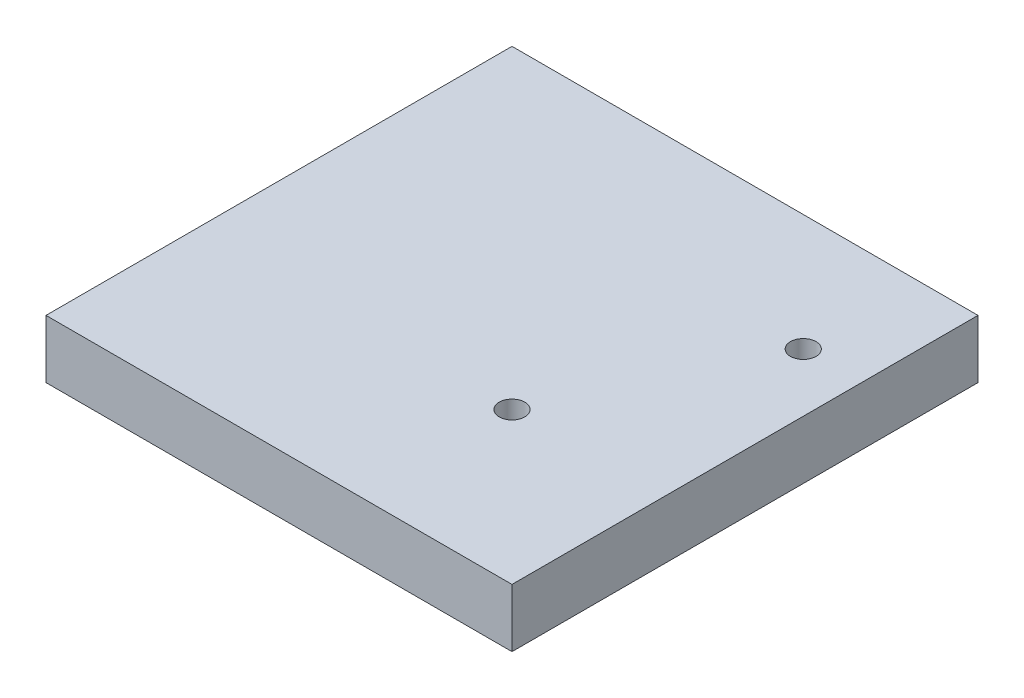
from build123d import *

# Parameters (mm, degrees)
SKETCH1_W           = 40
SKETCH1_H           = 40
SKETCH1_R           = 1.1
BOSS_EXTRUDE1_DEPTH = 5


with BuildPart() as part:
    # Sketch1 → Boss-Extrude1 (new body)
    with BuildSketch(Plane(origin=(0, 0, 0), x_dir=(1, 0, 0), z_dir=(0, 1, 0))):
        with Locations((20, 20)):
            Rectangle(SKETCH1_W, SKETCH1_H)
        with Locations((27, 13)):
            Circle(SKETCH1_R, mode=Mode.SUBTRACT)
        with Locations((35, 30)):
            Circle(SKETCH1_R, mode=Mode.SUBTRACT)
    extrude(amount=BOSS_EXTRUDE1_DEPTH)


solid = part.part
